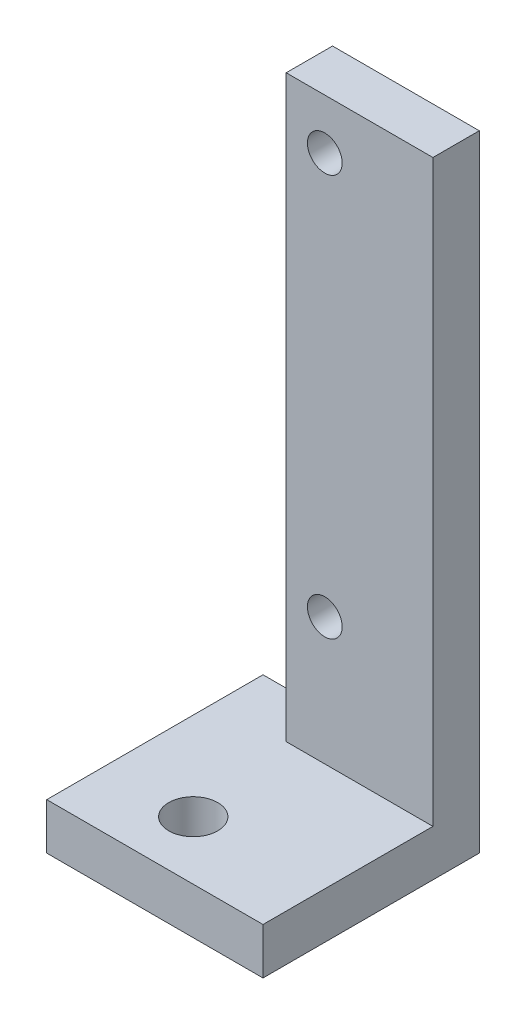
from build123d import *

# Parameters (mm, degrees)
SKETCH1_W               = 10
SKETCH1_H               = 10
SKETCH1_H_2             = 65
SKETCH1_R               = 2.25
BOSS_EXTRUDE1_DEPTH     = 6
SKETCH2_W               = 28
SKETCH2_H               = 28
SKETCH2_R               = 3.175
BOSS_EXTRUDE2_DEPTH     = 6
SKETCH3_W               = 6
SKETCH3_H               = 75
BOSS_EXTRUDE3_DEPTH     = 9
SKETCH4_W               = 54.205081497
SKETCH4_H               = 103.631562047
CUT_EXTRUDE1_DEPTH      = 23
CUT_EXTRUDE1_DEPTH_BACK = 7


with BuildPart() as part:
    # Sketch1 → Boss-Extrude1 (new body)
    with BuildSketch(Plane.XY):
        with Locations((0, -37.5)):
            Rectangle(SKETCH1_W, SKETCH1_H)
        Rectangle(SKETCH1_W, SKETCH1_H_2)
        with Locations((0, 26)):
            Circle(SKETCH1_R, mode=Mode.SUBTRACT)
        with Locations((0, -26)):
            Circle(SKETCH1_R, mode=Mode.SUBTRACT)
    extrude(amount=BOSS_EXTRUDE1_DEPTH)



with BuildPart() as body_2:
    # Sketch2 → Boss-Extrude2 (new body)
    with BuildSketch(Plane.XZ.offset(42.5)):
        with Locations((0, 14)):
            Rectangle(SKETCH2_W, SKETCH2_H)
        with Locations((2.6, 20.429948245)):
            Circle(SKETCH2_R, mode=Mode.SUBTRACT)
    extrude(amount=BOSS_EXTRUDE2_DEPTH)


with BuildPart() as part_1:
    add(part.part)

    add(body_2.part)  # Boss-Extrude3 merges body 2
    # Sketch3 → Boss-Extrude3 (add)
    with BuildSketch(Plane.ZY.offset(5)):
        with Locations((3, -5)):
            Rectangle(SKETCH3_W, SKETCH3_H)
    extrude(amount=BOSS_EXTRUDE3_DEPTH)

    # Mirror1: part across plane


with BuildPart() as part_2:
    add(part_1.part)
    add(part_1.part.mirror(Plane(origin=(-14, -48.5, 0), x_dir=(0, 0, 1), z_dir=(-1, 0, 0))))

    # Sketch4 → Cut-Extrude1 (cut, two sides)
    with BuildSketch(Plane.XY.offset(6)) as cut_extrude1_sk:
        with Locations((13.102540749, -19.315781024)):
            Rectangle(SKETCH4_W, SKETCH4_H)
    extrude(amount=CUT_EXTRUDE1_DEPTH, mode=Mode.SUBTRACT)
    extrude(cut_extrude1_sk.sketch, amount=-CUT_EXTRUDE1_DEPTH_BACK, mode=Mode.SUBTRACT)


solid = part_2.part
